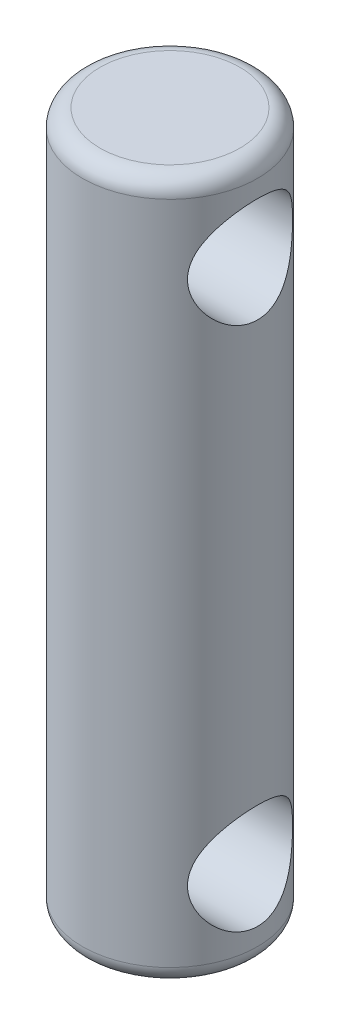
from build123d import *

# Parameters (mm, degrees)
SKETCH1_R           = 2.5
BOSS_EXTRUDE1_DEPTH = 20
SKETCH2_R           = 1.5
CUT_EXTRUDE1_DEPTH  = 5
FILLET1_R           = 0.5


with BuildPart() as part:
    # Sketch1 → Boss-Extrude1 (new body)
    with BuildSketch(Plane(origin=(0, 0, 0), x_dir=(1, 0, 0), z_dir=(0, 1, 0))):
        Circle(SKETCH1_R)
    extrude(amount=BOSS_EXTRUDE1_DEPTH)

    # Sketch2 → Cut-Extrude1 (cut, symmetric)
    with BuildSketch(Plane(origin=(0, 0, 0), x_dir=(0, 0, -1), z_dir=(1, 0, 0))):
        with Locations((0, 17.5)):
            Circle(SKETCH2_R)
        with Locations((0, 2.5)):
            Circle(SKETCH2_R)
    extrude(amount=CUT_EXTRUDE1_DEPTH, both=True, mode=Mode.SUBTRACT)

    # Fillet1
    fillet1_edges = [part.edges().sort_by_distance(p)[0] for p in [
        (-2.5, 0, 0),
        (-2.5, 20, 0),
    ]]
    fillet(fillet1_edges, radius=FILLET1_R)


solid = part.part
